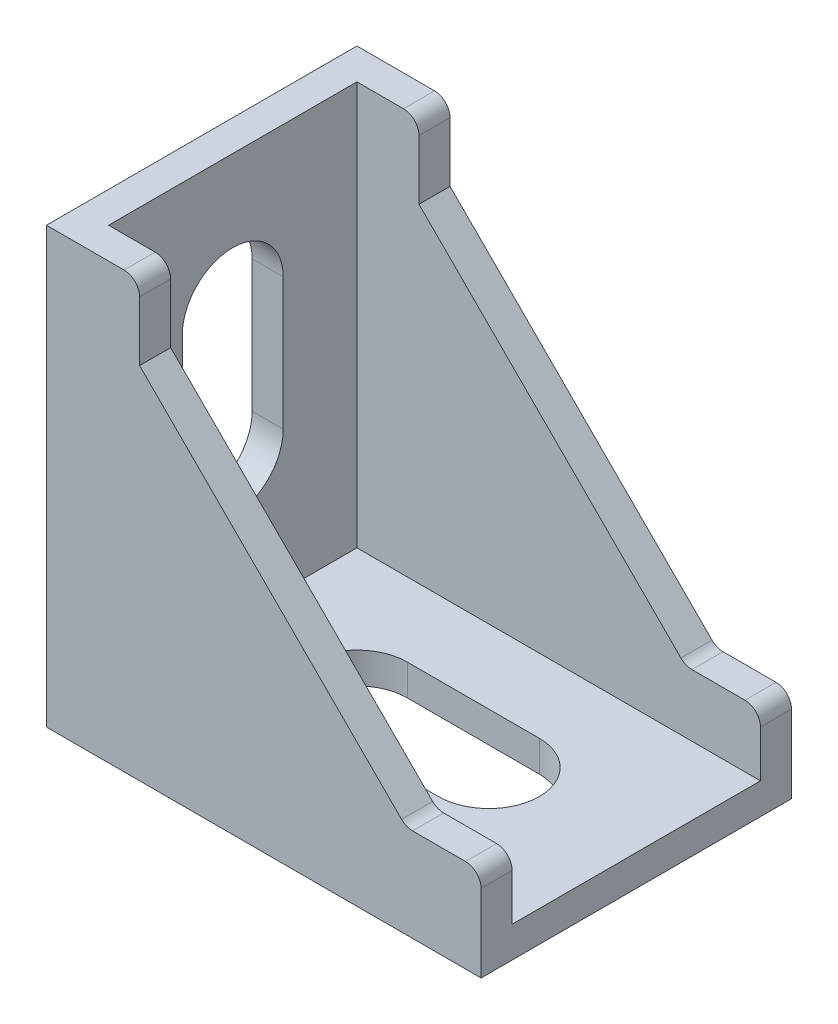
from build123d import *

# Parameters (mm, degrees)
EXTRUDE_1_DEPTH     = 20
SKETCH_2_W          = 16
SKETCH_2_H          = 26
CUT_EXTRUDE_1_DEPTH = 26
CUT_EXTRUDE_2_REACH = 4
CUT_EXTRUDE_3_REACH = 4
FILLET_1_R          = 1


with BuildPart() as part:
    # 草图1 → 凸台-拉伸1 (new body)
    with BuildSketch(Plane.XY):
        Polygon((0, 0), (0, 28), (6, 28), (6, 23.169014085), (23.169014085, 6), (28, 6), (28, 0), align=None)
    extrude(amount=EXTRUDE_1_DEPTH)

    # 草图2 → 切除-拉伸1 (cut)
    with BuildSketch(Plane(origin=(28, 0, 0), x_dir=(0, 0, -1), z_dir=(1, 0, 0))):
        with Locations((-10, 15)):
            Rectangle(SKETCH_2_W, SKETCH_2_H)
    extrude(amount=-CUT_EXTRUDE_1_DEPTH, mode=Mode.SUBTRACT)

    # 草图3 → 切除-拉伸2 (cut, up to next)
    with BuildSketch(Plane(origin=(2, 0, 0), x_dir=(0, 0, -1), z_dir=(1, 0, 0)), mode=Mode.PRIVATE) as cut_extrude_2_sk1:
        with BuildLine():
            Line((-13.25, 11), (-13.25, 19.5))
            ThreePointArc((-13.25, 19.5), (-10, 22.75), (-6.75, 19.5))
            Line((-6.75, 19.5), (-6.75, 11))
            ThreePointArc((-6.75, 11), (-10, 7.75), (-13.25, 11))
        make_face()
    cut_extrude_2_tool1 = extrude(cut_extrude_2_sk1.sketch, amount=-CUT_EXTRUDE_2_REACH, mode=Mode.PRIVATE) & part.part
    add(cut_extrude_2_tool1.solids().sort_by_distance((2, 15.25, 10))[0], mode=Mode.SUBTRACT)

    # 草图4 → 切除-拉伸3 (cut, up to next)
    with BuildSketch(Plane(origin=(0, 2, 2), x_dir=(1, 0, 0), z_dir=(0, 1, 0)), mode=Mode.PRIVATE) as cut_extrude_3_sk1:
        with BuildLine():
            Line((10, -4.75), (18.5, -4.75))
            ThreePointArc((18.5, -4.75), (21.75, -8), (18.5, -11.25))
            Line((18.5, -11.25), (10, -11.25))
            ThreePointArc((10, -11.25), (6.75, -8), (10, -4.75))
        make_face()
    cut_extrude_3_tool1 = extrude(cut_extrude_3_sk1.sketch, amount=-CUT_EXTRUDE_3_REACH, mode=Mode.PRIVATE) & part.part
    add(cut_extrude_3_tool1.solids().sort_by_distance((14.25, 2, 10))[0], mode=Mode.SUBTRACT)

    # 圆角1
    fillet_1_edges = [part.edges().sort_by_distance(p)[0] for p in [
        (6, 28, 19),
        (23.169014085, 6, 19),
        (28, 6, 19),
        (6, 28, 1),
        (23.169014085, 6, 1),
        (28, 6, 1),
    ]]
    fillet(fillet_1_edges, radius=FILLET_1_R)


solid = part.part
